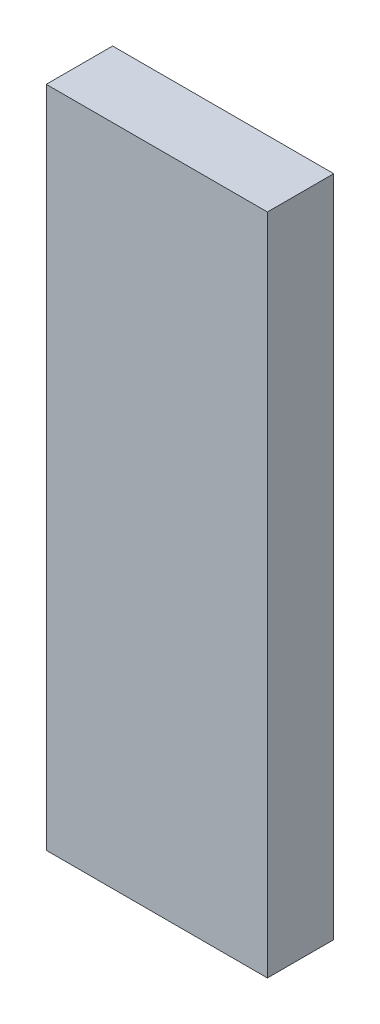
from build123d import *

# Parameters (mm, degrees)
SKETCH2_W           = 10
SKETCH2_H           = 3
BOSS_EXTRUDE1_DEPTH = 30


with BuildPart() as part:
    # Sketch2 → Boss-Extrude1 (new body)
    with BuildSketch(Plane(origin=(0, 0, 0), x_dir=(1, 0, 0), z_dir=(0, 1, 0))):
        Rectangle(SKETCH2_W, SKETCH2_H)
    extrude(amount=BOSS_EXTRUDE1_DEPTH)


solid = part.part
